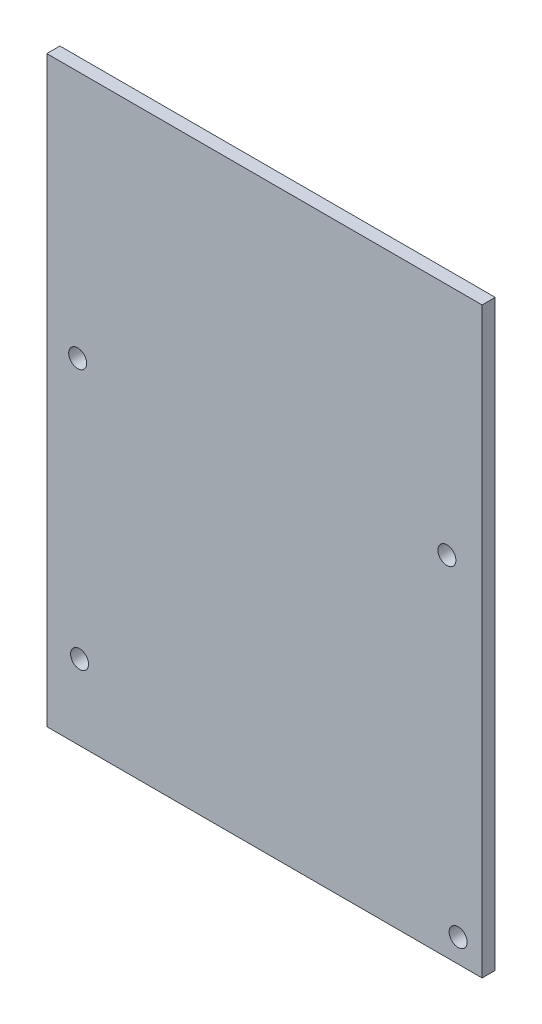
from build123d import *

# Parameters (mm, degrees)
SKETCH1_W                 = 59
SKETCH1_H                 = 79
EXTRUDE1_DEPTH            = 1.778
F_2_CLEARANCE_HOLE1_D     = 2.4384
F_2_CLEARANCE_HOLE1_DEPTH = 6.35
F_2_CLEARANCE_HOLE1_TIP   = 0.732569267


with BuildPart() as part:
    # Sketch1 → Extrude1 (new body)
    with BuildSketch(Plane.XY):
        with Locations((0, 1)):
            Rectangle(SKETCH1_W, SKETCH1_H)
    extrude(amount=EXTRUDE1_DEPTH)

    # #2 Clearance Hole1
    with Locations(Plane(origin=(-25.055, -28.34, 1.778), x_dir=(1, 0, 0), z_dir=(0, 0, 1))):
        with Locations((0, 0), (-0.254, 35.179), (49.784, 37.084), (51.308, -6.985)):
            Hole(F_2_CLEARANCE_HOLE1_D / 2, depth=F_2_CLEARANCE_HOLE1_DEPTH)
            with Locations((0, 0, -(F_2_CLEARANCE_HOLE1_DEPTH + F_2_CLEARANCE_HOLE1_TIP / 2))):  # 118° drill point
                Cone(0, F_2_CLEARANCE_HOLE1_D / 2, F_2_CLEARANCE_HOLE1_TIP, mode=Mode.SUBTRACT)


solid = part.part
